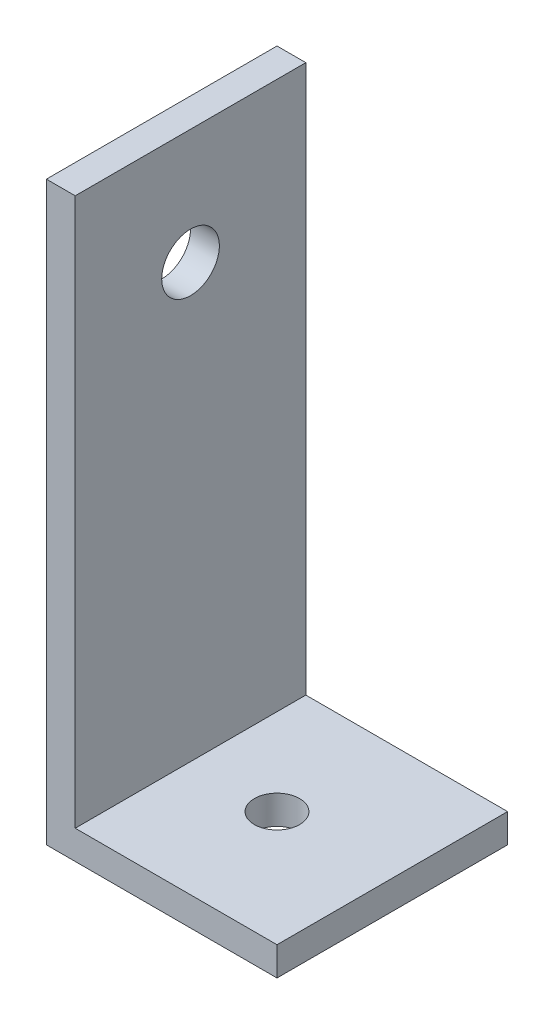
from build123d import *

# Parameters (mm, degrees)
BOSS_EXTRUDE1_DEPTH            = 25.4
SKETCH2_R                      = 3.175
CUT_EXTRUDE1_DEPTH             = 26.4
F_9_0_196_DIAMETER_HOLE1_D     = 4.9784
F_9_0_196_DIAMETER_HOLE1_DEPTH = 3.175


with BuildPart() as part:
    # Sketch1 → Boss-Extrude1 (new body)
    with BuildSketch(Plane.XY):
        Polygon((0, 0), (0, 63.5), (3.175, 63.5), (3.175, 3.175), (25.4, 3.175), (25.4, 0), align=None)
    extrude(amount=BOSS_EXTRUDE1_DEPTH)

    # Sketch2 → Cut-Extrude1 (cut, through all)
    with BuildSketch(Plane.ZY):
        with Locations((12.7, 50.8)):
            Circle(SKETCH2_R)
    extrude(amount=-CUT_EXTRUDE1_DEPTH, mode=Mode.SUBTRACT)

    # #9 (0.196) Diameter Hole1
    with Locations(Plane(origin=(0, 0, 0), x_dir=(-1, 0, 0), z_dir=(0, -1, 0))):
        with Locations((-12.7, -12.7)):
            Hole(F_9_0_196_DIAMETER_HOLE1_D / 2, depth=F_9_0_196_DIAMETER_HOLE1_DEPTH)


solid = part.part
